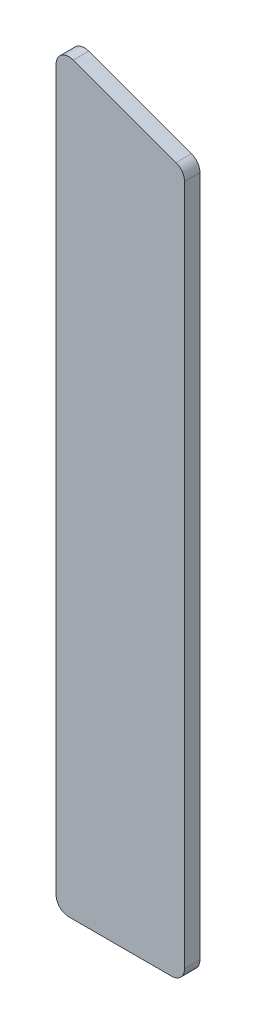
from build123d import *

# Parameters (mm, degrees)
BASE_EXTRUDE_DEPTH = 6


with BuildPart() as part:
    # Sketch1 → Base-Extrude (new body)
    with BuildSketch(Plane.XY):
        with BuildLine():
            Line((-20, 0), (20, 0))
            ThreePointArc((20, 0), (23.535533906, 1.464466094), (25, 5))
            Line((25, 5), (25, 270.441190629))
            ThreePointArc((25, 270.441190629), (24.095760221, 273.309072811), (21.710100717, 275.139653733))
            Line((21.710100717, 275.139653733), (-18.289899283, 289.698463104))
            ThreePointArc((-18.289899283, 289.698463104), (-22.867882182, 289.095760221), (-25, 285))
            Line((-25, 285), (-25, 5))
            ThreePointArc((-25, 5), (-23.535533906, 1.464466094), (-20, 0))
        make_face()
    extrude(amount=BASE_EXTRUDE_DEPTH)


solid = part.part
